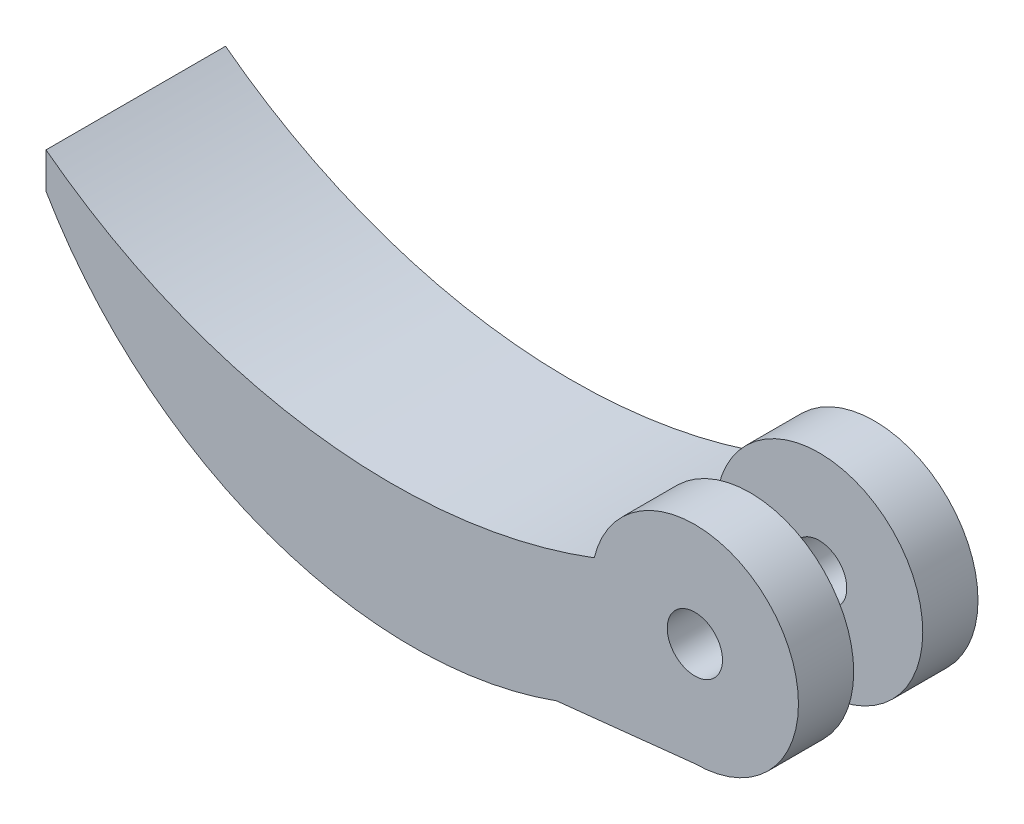
from build123d import *

# Parameters (mm, degrees)
CROQUIS1_R              = 7.5
CROQUIS1_R_2            = 2
SALIENTE_EXTRUIR1_DEPTH = 4
CROQUIS2_R              = 2.193779366
SALIENTE_EXTRUIR2_DEPTH = 5
CROQUIS3_R              = 7.5
CROQUIS3_R_2            = 2
SALIENTE_EXTRUIR3_DEPTH = 4
CROQUIS4_R              = 2.193779366
CORTAR_EXTRUIR1_DEPTH   = 14
SALIENTE_EXTRUIR4_DEPTH = 13


with BuildPart() as part:
    # Croquis1 → Saliente-Extruir1 (new body)
    with BuildSketch(Plane.XY):
        Circle(CROQUIS1_R)
        Circle(CROQUIS1_R_2, mode=Mode.SUBTRACT)
    extrude(amount=SALIENTE_EXTRUIR1_DEPTH)



with BuildPart() as body_2:
    # Croquis2 → Saliente-Extruir2 (new body)
    with BuildSketch(Plane(origin=(0, 0, 0), x_dir=(-1, 0, 0), z_dir=(0, 0, -1))):
        Circle(CROQUIS2_R)
    extrude(amount=SALIENTE_EXTRUIR2_DEPTH)

    # Croquis4 → Cortar-Extruir1 (cut)
    with BuildSketch(Plane(origin=(0, 0, -5), x_dir=(-1, 0, 0), z_dir=(0, 0, -1))):
        Circle(CROQUIS4_R)
    extrude(amount=-CORTAR_EXTRUIR1_DEPTH, mode=Mode.SUBTRACT)


with BuildPart() as body_3:
    # Croquis3 → Saliente-Extruir3 (new body)
    with BuildSketch(Plane(origin=(0, 0, -5), x_dir=(-1, 0, 0), z_dir=(0, 0, -1))):
        Circle(CROQUIS3_R)
        Circle(CROQUIS3_R_2, mode=Mode.SUBTRACT)
    extrude(amount=SALIENTE_EXTRUIR3_DEPTH)


with BuildPart() as part_1:
    add(part.part)

    add(body_3.part)  # Saliente-Extruir4 merges body 3
    # Croquis5 → Saliente-Extruir4 (add)
    with BuildSketch(Plane.XY.offset(4)):
        with BuildLine():
            Line((-10.009282788, -8.566914266), (0, -7.5))
            ThreePointArc((0, -7.5), (-5.895156044, -4.636500319), (-7.288771435, 1.76743061))
            ThreePointArc((-7.288771435, 1.76743061), (-27.875344012, -0.49038836), (-46.981845806, 7.5))
            Line((-46.981845806, 7.5), (-46.981845806, 4.90393409))
            ThreePointArc((-46.981845806, 4.90393409), (-30.939741801, -8.539865418), (-10.009282788, -8.566914266))
        make_face()
    extrude(amount=-SALIENTE_EXTRUIR4_DEPTH)


solid = part_1.part
